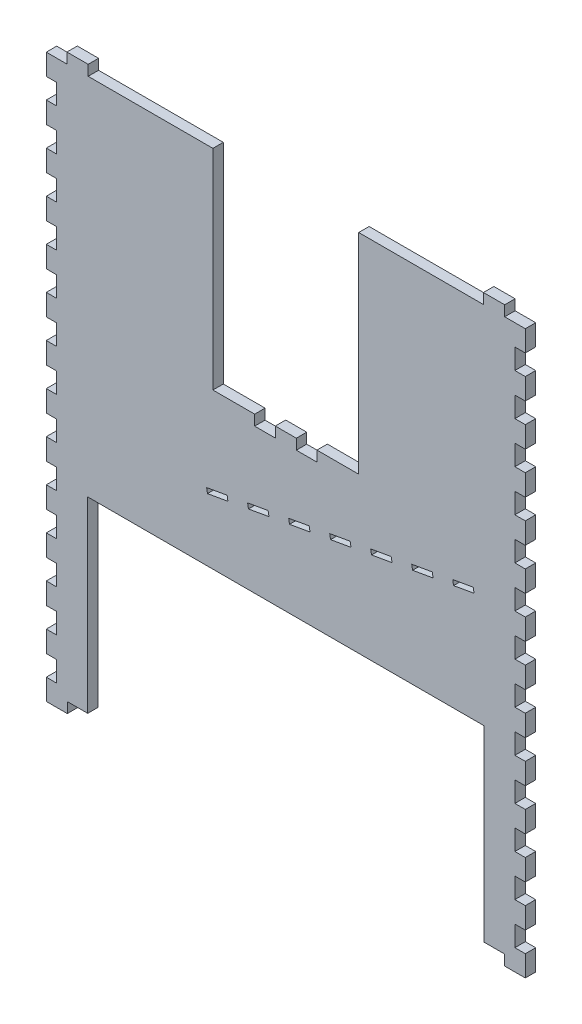
from build123d import *

# Parameters (mm, degrees)
BOSS_EXTRUDE1_DEPTH = 6.35


with BuildPart() as part:
    # Sketch1 → Boss-Extrude1 (new body)
    with BuildSketch(Plane.XY):
        Polygon((0, 0), (12.573, 0), (12.573, 6.35), (25.527, 6.35), (25.527, 0), (101.6, 0), (101.6, -127.635), (127.0635, -127.635), (127.0635, -133.985), (139.6365, -133.985), (139.6365, -127.635), (152.4635, -127.635), (152.4635, -133.985), (165.0365, -133.985), (165.0365, -127.635), (190.5, -127.635), (190.5, 0), (266.573, 0), (266.573, 6.35), (279.527, 6.35), (279.527, 0), (292.1, 0), (292.1, -12.827), (285.75, -12.827), (285.75, -25.273), (292.1, -25.273), (292.1, -38.227), (285.75, -38.227), (285.75, -50.673), (292.1, -50.673), (292.1, -63.627), (285.75, -63.627), (285.75, -76.073), (292.1, -76.073), (292.1, -89.027), (285.75, -89.027), (285.75, -101.473), (292.1, -101.473), (292.1, -114.427), (285.75, -114.427), (285.75, -126.873), (292.1, -126.873), (292.1, -139.827), (285.75, -139.827), (285.75, -152.273), (292.1, -152.273), (292.1, -165.227), (285.75, -165.227), (285.75, -177.673), (292.1, -177.673), (292.1, -190.627), (285.75, -190.627), (285.75, -203.073), (292.1, -203.073), (292.1, -216.027), (285.75, -216.027), (285.75, -228.473), (292.1, -228.473), (292.1, -241.427), (285.75, -241.427), (285.75, -253.873), (292.1, -253.873), (292.1, -266.827), (285.75, -266.827), (285.75, -279.273), (292.1, -279.273), (292.1, -292.227), (285.75, -292.227), (285.75, -304.673), (292.1, -304.673), (292.1, -317.627), (285.75, -317.627), (285.75, -330.073), (292.1, -330.073), (292.1, -342.9), (279.273, -342.9), (279.273, -336.55), (266.827, -336.55), (266.827, -222.25), (25.273, -222.25), (25.273, -336.55), (12.827, -336.55), (12.827, -342.9), (0, -342.9), (0, -330.073), (6.35, -330.073), (6.35, -317.627), (0, -317.627), (0, -304.673), (6.35, -304.673), (6.35, -292.227), (0, -292.227), (0, -279.273), (6.35, -279.273), (6.35, -266.827), (0, -266.827), (0, -253.873), (6.35, -253.873), (6.35, -241.427), (0, -241.427), (0, -228.473), (6.35, -228.473), (6.35, -216.027), (0, -216.027), (0, -203.073), (6.35, -203.073), (6.35, -190.627), (0, -190.627), (0, -177.673), (6.35, -177.673), (6.35, -165.227), (0, -165.227), (0, -152.273), (6.35, -152.273), (6.35, -139.827), (0, -139.827), (0, -126.873), (6.35, -126.873), (6.35, -114.427), (0, -114.427), (0, -101.473), (6.35, -101.473), (6.35, -89.027), (0, -89.027), (0, -76.073), (6.35, -76.073), (6.35, -63.627), (0, -63.627), (0, -50.673), (6.35, -50.673), (6.35, -38.227), (0, -38.227), (0, -25.273), (6.35, -25.273), (6.35, -12.827), (0, -12.827), align=None)
        Polygon((260.870458318, -155.351665797), (248.363399855, -157.556997654), (247.842941537, -154.605331856), (260.35, -152.4), align=None, mode=Mode.SUBTRACT)
        Polygon((235.856341392, -159.76232951), (223.349282928, -161.967661366), (222.82882461, -159.015995569), (235.335883073, -156.810663713), align=None, mode=Mode.SUBTRACT)
        Polygon((210.842224465, -164.172993223), (198.335166002, -166.378325079), (197.814707684, -163.426659282), (210.321766147, -161.221327425), align=None, mode=Mode.SUBTRACT)
        Polygon((185.828107539, -168.583656936), (173.321049075, -170.788988792), (172.800590757, -167.837322995), (185.30764922, -165.631991138), align=None, mode=Mode.SUBTRACT)
        Polygon((160.813990612, -172.994320648), (148.306932149, -175.199652505), (147.786473831, -172.247986707), (160.293532294, -170.042654851), align=None, mode=Mode.SUBTRACT)
        Polygon((135.799873686, -177.404984361), (123.292815222, -179.610316217), (122.772356904, -176.65865042), (135.279415367, -174.453318564), align=None, mode=Mode.SUBTRACT)
        Polygon((110.785756759, -181.815648074), (98.278698296, -184.02097993), (97.758239978, -181.069314133), (110.265298441, -178.863982276), align=None, mode=Mode.SUBTRACT)
    extrude(amount=BOSS_EXTRUDE1_DEPTH)


solid = part.part
